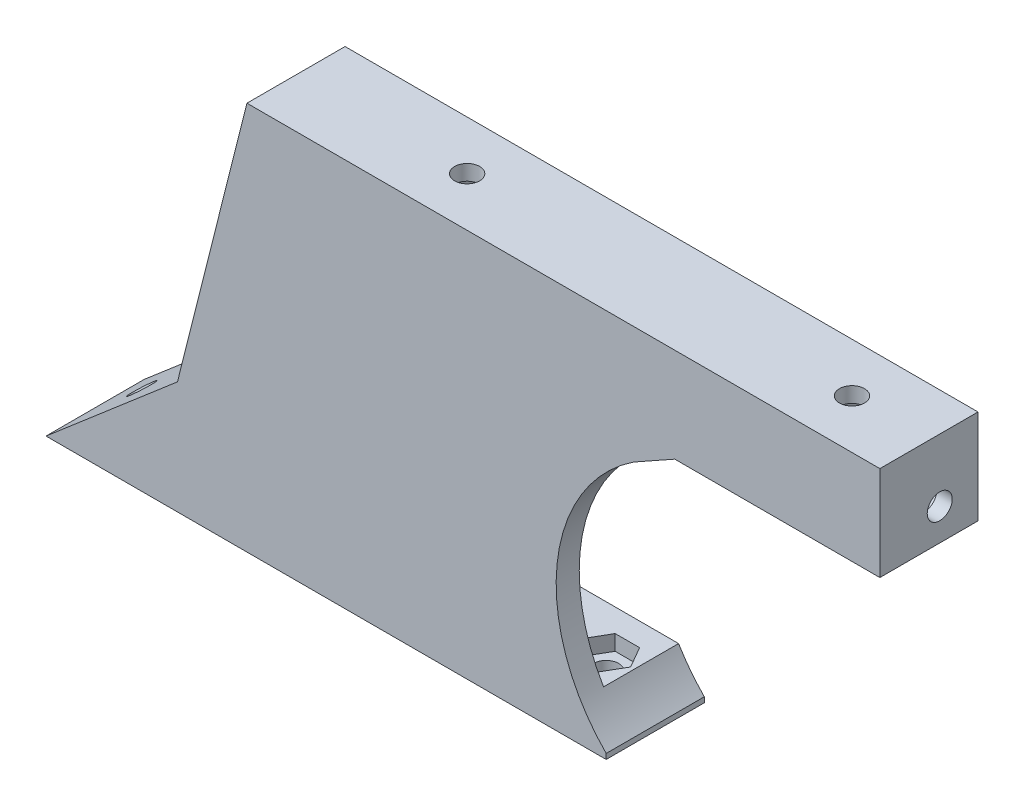
from build123d import *

# Parameters (mm, degrees)
SALIENTE_EXTRUIR1_DEPTH = 3
SALIENTE_EXTRUIR2_DEPTH = 9.75
CROQUIS4_R              = 1.625
CORTAR_EXTRUIR1_DEPTH   = 5
CORTAR_EXTRUIR2_DEPTH   = 2
CROQUIS6_R              = 1.625
CORTAR_EXTRUIR3_DEPTH   = 9
CORTAR_EXTRUIR4_DEPTH   = 10
CROQUIS10_R             = 1.625
SALIENTE_EXTRUIR3_DEPTH = 2
CORTAR_EXTRUIR5_DEPTH   = 5
CROQUIS14_R             = 1.625
SALIENTE_EXTRUIR4_DEPTH = 3
CROQUIS15_R             = 1.625
CORTAR_EXTRUIR6_DEPTH   = 4
CORTAR_EXTRUIR7_DEPTH   = 2
CROQUIS17_R             = 1.625
CORTAR_EXTRUIR9_DEPTH   = 4
CORTAR_EXTRUIR10_DEPTH  = 2


with BuildPart() as part:
    # Croquis1 → Saliente-Extruir1 (new body)
    with BuildSketch(Plane.XY):
        with BuildLine():
            Line((-46.67593732, 50.511923567), (-55.699999998, 14.642073221))
            Line((-55.699999998, 14.642073221), (-72.78319995, 0))
            Line((-72.78319995, 0), (0, 0))
            Line((0, 0), (0, 0.68070798))
            ThreePointArc((0, 0.68070798), (-6.381456753, 18.806597842), (3.562657036, 35.25))
            Line((3.562657036, 35.25), (8.913300435, 38.25))
            Line((8.913300435, 38.25), (35.562657036, 38.25))
            Line((35.562657036, 38.25), (35.562657036, 50.511923567))
            Line((35.562657036, 50.511923567), (-46.67593732, 50.511923567))
        make_face()
    extrude(amount=-SALIENTE_EXTRUIR1_DEPTH)

    # Croquis2 → Saliente-Extruir2 (add)
    with BuildSketch(Plane(origin=(0, 0, -3), x_dir=(-1, 0, 0), z_dir=(0, 0, -1))):
        with BuildLine():
            Line((42.526447804, 46.511923567), (51.238983488, 11.880365447))
            Line((51.238983488, 11.880365447), (59.266443595, 5))
            Line((59.266443595, 5), (3.339079606, 5))
            ThreePointArc((3.339079606, 5), (1.801031086, 2.738703104), (0, 0.68070798))
            Line((0, 0.68070798), (0, 0))
            Line((0, 0), (72.78319995, 0))
            Line((72.78319995, 0), (55.699999998, 14.642073221))
            Line((55.699999998, 14.642073221), (46.67593732, 50.511923567))
            Line((46.67593732, 50.511923567), (-35.562657036, 50.511923567))
            Line((-35.562657036, 50.511923567), (-35.562657036, 38.25))
            Line((-35.562657036, 38.25), (-31.562657036, 38.25))
            Line((-31.562657036, 38.25), (-31.562657036, 46.511923567))
            Line((-31.562657036, 46.511923567), (42.526447804, 46.511923567))
        make_face()
    extrude(amount=SALIENTE_EXTRUIR2_DEPTH)

    # Croquis4 → Cortar-Extruir1 (cut)
    with BuildSketch(Plane.XZ):
        with Locations((-6.999999998, -7)):
            Circle(CROQUIS4_R)
        with Locations((-52.78319995, -7)):
            Circle(CROQUIS4_R)
    extrude(amount=-CORTAR_EXTRUIR1_DEPTH, mode=Mode.SUBTRACT)

    # Croquis5 → Cortar-Extruir2 (cut)
    with BuildSketch(Plane(origin=(0, 5, 0), x_dir=(1, 0, 0), z_dir=(0, 1, 0))):
        Polygon((-10.179999998, 7), (-8.589999998, 4.246039216), (-5.409999998, 4.246039216), (-3.819999998, 7), (-5.409999998, 9.753960784), (-8.589999998, 9.753960784), align=None)
        Polygon((-49.60319995, 7), (-51.19319995, 9.753960784), (-54.37319995, 9.753960784), (-55.96319995, 7), (-54.37319995, 4.246039216), (-51.19319995, 4.246039216), align=None)
    extrude(amount=-CORTAR_EXTRUIR2_DEPTH, mode=Mode.SUBTRACT)

    # Croquis6 → Cortar-Extruir3 (cut)
    with BuildSketch(Plane(origin=(-30.824200619, 35.963211942, 0), x_dir=(0.759271307, 0.650774217, 0), z_dir=(-0.650774217, 0.759271307, 0))):
        with Locations((-47.262195378, 6.375)):
            Circle(CROQUIS6_R)
    extrude(amount=-CORTAR_EXTRUIR3_DEPTH, mode=Mode.SUBTRACT)

    # Croquis9 → Cortar-Extruir4 (cut)
    with BuildSketch(Plane(origin=(-30.824200619, 35.963211942, 0), x_dir=(0.759271307, 0.650774217, 0), z_dir=(-0.650774217, 0.759271307, 0))):
        Polygon((-50.432195378, 6.375), (-48.847195378, 3.62969947), (-45.677195378, 3.62969947), (-44.092195378, 6.375), (-45.677195378, 9.12030053), (-48.847195378, 9.12030053), align=None)
    extrude(amount=-CORTAR_EXTRUIR4_DEPTH, mode=Mode.SUBTRACT)

    # Croquis10 → Saliente-Extruir3 (add)
    with BuildSketch(Plane(origin=(-30.824200619, 35.963211942, 0), x_dir=(0.759271307, 0.650774217, 0), z_dir=(-0.650774217, 0.759271307, 0))):
        Polygon((-50.432195378, 6.375), (-48.847195378, 3.62969947), (-45.677195378, 3.62969947), (-44.092195378, 6.375), (-45.677195378, 9.12030053), (-48.847195378, 9.12030053), align=None)
        with Locations((-47.262195378, 6.375)):
            Circle(CROQUIS10_R, mode=Mode.SUBTRACT)
    extrude(amount=-SALIENTE_EXTRUIR3_DEPTH)

    # Croquis13 → Cortar-Extruir5 (cut)
    with BuildSketch(Plane(origin=(-55.848866467, 14.050342186, 0), x_dir=(0, 0, 1), z_dir=(-0.969781373, 0.24397559, 0))):
        Polygon((-6.375, 20.547396855), (-3.621039216, 22.137396855), (-3.621039216, 25.317396855), (-6.375, 26.907396855), (-9.128960784, 25.317396855), (-9.128960784, 22.137396855), align=None)
    extrude(amount=-CORTAR_EXTRUIR5_DEPTH, mode=Mode.SUBTRACT)

    # Croquis14 → Saliente-Extruir4 (add)
    with BuildSketch(Plane(origin=(-55.848866467, 14.050342186, 0), x_dir=(0, 0, 1), z_dir=(-0.969781373, 0.24397559, 0))):
        Polygon((-6.375, 26.907396855), (-9.128960784, 25.317396855), (-9.128960784, 22.137396855), (-6.375, 20.547396855), (-3.621039216, 22.137396855), (-3.621039216, 25.317396855), align=None)
        with Locations((-6.375, 23.727396855)):
            Circle(CROQUIS14_R, mode=Mode.SUBTRACT)
    extrude(amount=-SALIENTE_EXTRUIR4_DEPTH)

    # Croquis15 → Cortar-Extruir6 (cut)
    with BuildSketch(Plane(origin=(0, 50.511923567, 0), x_dir=(1, 0, 0), z_dir=(0, 1, 0))):
        with Locations((25.562657036, 6.375)):
            Circle(CROQUIS15_R)
        with Locations((-24.437342964, 6.375)):
            Circle(CROQUIS15_R)
    extrude(amount=-CORTAR_EXTRUIR6_DEPTH, mode=Mode.SUBTRACT)

    # Croquis16 → Cortar-Extruir7 (cut)
    with BuildSketch(Plane.XZ.offset(-46.511923567)):
        Polygon((22.382657036, -6.375), (23.972657036, -9.128960784), (27.152657036, -9.128960784), (28.742657036, -6.375), (27.152657036, -3.621039216), (23.972657036, -3.621039216), align=None)
        Polygon((-21.257342964, -6.375), (-22.847342964, -3.621039216), (-26.027342964, -3.621039216), (-27.617342964, -6.375), (-26.027342964, -9.128960784), (-22.847342964, -9.128960784), align=None)
    extrude(amount=-CORTAR_EXTRUIR7_DEPTH, mode=Mode.SUBTRACT)

    # Croquis17 → Cortar-Extruir9 (cut)
    with BuildSketch(Plane(origin=(35.562657036, 0, 0), x_dir=(0, 0, -1), z_dir=(1, 0, 0))):
        with Locations((7.777494034, 42.38)):
            Circle(CROQUIS17_R)
    extrude(amount=-CORTAR_EXTRUIR9_DEPTH, mode=Mode.SUBTRACT)

    # Croquis18 → Cortar-Extruir10 (cut)
    with BuildSketch(Plane.ZY.offset(-31.562657036)):
        Polygon((-7.777494034, 39.2), (-5.02353325, 40.79), (-5.02353325, 43.97), (-7.777494034, 45.56), (-10.531454818, 43.97), (-10.531454818, 40.79), align=None)
    extrude(amount=-CORTAR_EXTRUIR10_DEPTH, mode=Mode.SUBTRACT)


solid = part.part
